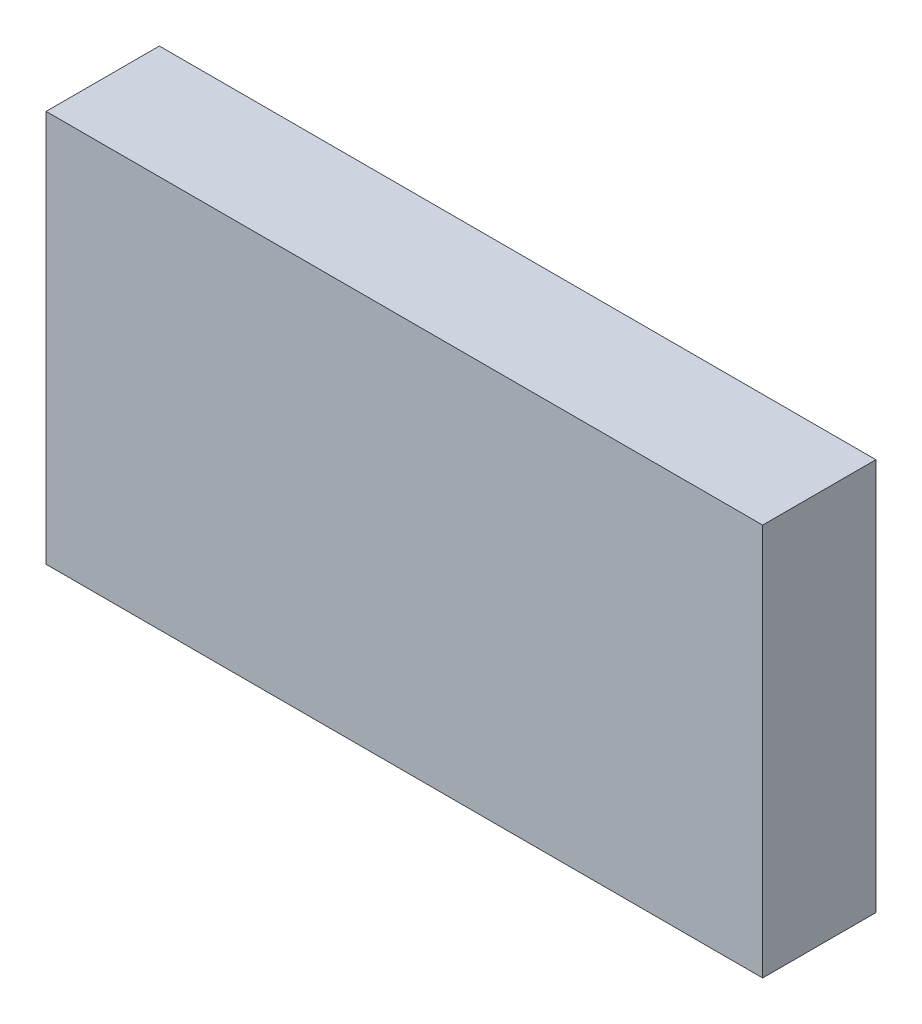
from build123d import *

# Parameters (mm, degrees)
SKETCH1_W               = 6.327
SKETCH1_H               = 3.4635
COMPONENT_OUTLINE_DEPTH = 1


with BuildPart() as part:
    # Sketch1 → Component_Outline (new body)
    with BuildSketch(Plane.XY):
        with Locations((0, 0.03175)):
            Rectangle(SKETCH1_W, SKETCH1_H)
    extrude(amount=COMPONENT_OUTLINE_DEPTH)


solid = part.part
